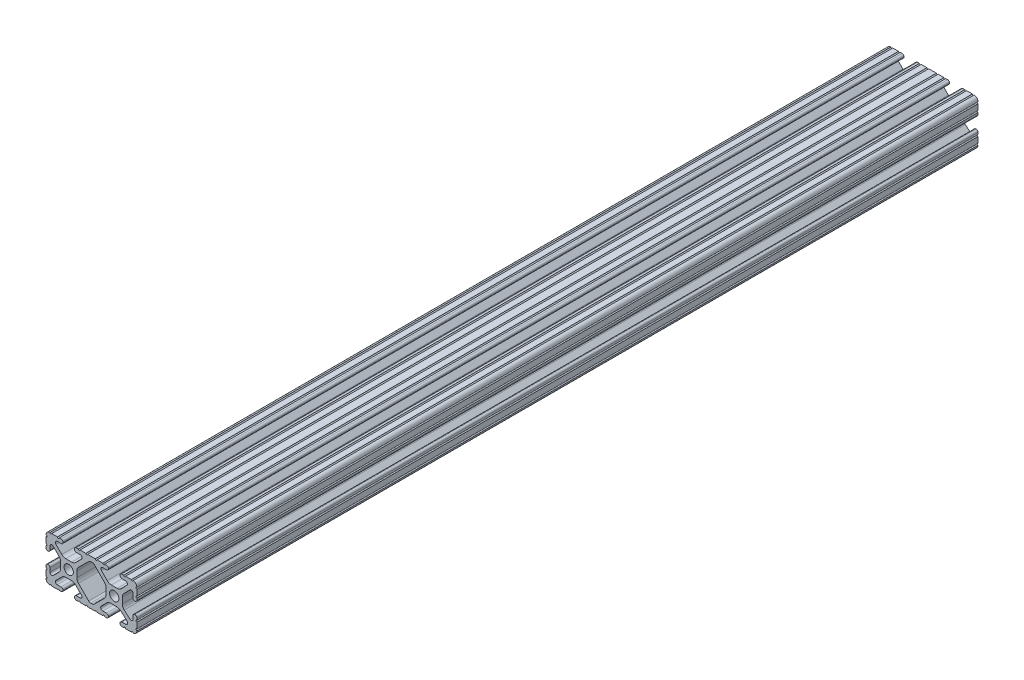
from build123d import *

# Parameters (mm, degrees)
SKETCH1_R      = 2.6035
EXTRUDE1_DEPTH = 235


with BuildPart() as part:
    # Sketch1 → Extrude1 (new body, symmetric)
    with BuildSketch(Plane.XY):
        with BuildLine():
            Line((9.5504, 12.7), (6.33310265, 12.7))
            ThreePointArc((6.33310265, 12.7), (5.82510265, 12.192), (5.31710265, 12.7))
            Line((5.31710265, 12.7), (4.28745015, 12.7))
            ThreePointArc((4.28745015, 12.7), (3.545730386, 12.392769614), (3.2385, 11.65104985))
            Line((3.2385, 11.65104985), (3.2385, 11.53922))
            ThreePointArc((3.2385, 11.53922), (3.545750844, 10.797450844), (4.28752, 10.4902))
            Line((4.28752, 10.4902), (6.416384363, 10.4902))
            ThreePointArc((6.416384363, 10.4902), (7.352502933, 9.869096983), (7.144087081, 8.765172272))
            Line((7.144087081, 8.765172272), (3.918993479, 5.455112286))
            ThreePointArc((3.918993479, 5.455112286), (2.878994274, 4.745442459), (1.644932584, 4.4958))
            Line((1.644932584, 4.4958), (-1.616682165, 4.4958))
            ThreePointArc((-1.616682165, 4.4958), (-2.845669047, 4.743306833), (-3.883044811, 5.447238587))
            Line((-3.883044811, 5.447238587), (-7.135845881, 8.762652677))
            ThreePointArc((-7.135845881, 8.762652677), (-7.347408588, 9.867473037), (-6.410606615, 10.4902))
            Line((-6.410606615, 10.4902), (-4.28752, 10.4902))
            ThreePointArc((-4.28752, 10.4902), (-3.545750844, 10.797450844), (-3.2385, 11.53922))
            Line((-3.2385, 11.53922), (-3.2385, 11.65104985))
            ThreePointArc((-3.2385, 11.65104985), (-3.545730386, 12.392769614), (-4.28745015, 12.7))
            Line((-4.28745015, 12.7), (-5.31711535, 12.7))
            ThreePointArc((-5.31711535, 12.7), (-5.82511535, 12.192), (-6.33311535, 12.7))
            Line((-6.33311535, 12.7), (-9.55041905, 12.7))
            ThreePointArc((-9.55041905, 12.7), (-10.05841905, 12.192), (-10.56641905, 12.7))
            Line((-10.56641905, 12.7), (-14.83358095, 12.7))
            ThreePointArc((-14.83358095, 12.7), (-15.34158095, 12.192), (-15.84958095, 12.7))
            Line((-15.84958095, 12.7), (-19.06689735, 12.7))
            ThreePointArc((-19.06689735, 12.7), (-19.57489735, 12.192), (-20.08289735, 12.7))
            Line((-20.08289735, 12.7), (-21.11254985, 12.7))
            ThreePointArc((-21.11254985, 12.7), (-21.854269614, 12.392769614), (-22.1615, 11.65104985))
            Line((-22.1615, 11.65104985), (-22.1615, 11.53922))
            ThreePointArc((-22.1615, 11.53922), (-21.854249156, 10.797450844), (-21.11248, 10.4902))
            Line((-21.11248, 10.4902), (-18.983641037, 10.4902))
            ThreePointArc((-18.983641037, 10.4902), (-17.997291557, 9.829633109), (-18.232576693, 8.666071843))
            Line((-18.232576693, 8.666071843), (-21.509985098, 5.416263103))
            ThreePointArc((-21.509985098, 5.416263103), (-22.536720513, 4.734920264), (-23.745536121, 4.4958))
            Line((-23.745536121, 4.4958), (-27.054463879, 4.4958))
            ThreePointArc((-27.054463879, 4.4958), (-28.263279487, 4.734920264), (-29.290014902, 5.416263103))
            Line((-29.290014902, 5.416263103), (-32.567423307, 8.666071843))
            ThreePointArc((-32.567423307, 8.666071843), (-32.802708443, 9.829633109), (-31.816358963, 10.4902))
            Line((-31.816358963, 10.4902), (-29.68752, 10.4902))
            ThreePointArc((-29.68752, 10.4902), (-28.945750844, 10.797450844), (-28.6385, 11.53922))
            Line((-28.6385, 11.53922), (-28.6385, 11.65104985))
            ThreePointArc((-28.6385, 11.65104985), (-28.945730386, 12.392769614), (-29.68745015, 12.7))
            Line((-29.68745015, 12.7), (-30.71711535, 12.7))
            ThreePointArc((-30.71711535, 12.7), (-31.22511535, 12.192), (-31.73311535, 12.7))
            Line((-31.73311535, 12.7), (-34.9504, 12.7))
            ThreePointArc((-34.9504, 12.7), (-35.458323491, 12.192000006), (-35.966399977, 12.699846982))
            ThreePointArc((-35.966399977, 12.699846982), (-37.482522516, 12.082522516), (-38.099846982, 10.566399977))
            ThreePointArc((-38.099846982, 10.566399977), (-37.592000006, 10.058323491), (-38.1, 9.5504))
            Line((-38.1, 9.5504), (-38.1, 6.3330836))
            ThreePointArc((-38.1, 6.3330836), (-37.592, 5.8250836), (-38.1, 5.3170836))
            Line((-38.1, 5.3170836), (-38.1, 4.237520184))
            ThreePointArc((-38.1, 4.237520184), (-37.807393763, 3.531106237), (-37.100979816, 3.2385))
            Line((-37.100979816, 3.2385), (-36.93922, 3.2385))
            ThreePointArc((-36.93922, 3.2385), (-36.197450844, 3.545750844), (-35.8902, 4.28752))
            Line((-35.8902, 4.28752), (-35.8902, 6.334741132))
            ThreePointArc((-35.8902, 6.334741132), (-35.256026952, 7.286023527), (-34.134002553, 7.066535717))
            Line((-34.134002553, 7.066535717), (-30.847950853, 3.808156468))
            ThreePointArc((-30.847950853, 3.808156468), (-30.152759693, 2.774838327), (-29.908501877, 1.553619571))
            Line((-29.908501877, 1.553619571), (-29.908501877, -1.695179196))
            ThreePointArc((-29.908501877, -1.695179196), (-30.150738657, -2.911536421), (-30.840486065, -3.942289578))
            Line((-30.840486065, -3.942289578), (-34.131579576, -7.227386226))
            ThreePointArc((-34.131579576, -7.227386226), (-35.25444896, -7.449940594), (-35.8902, -6.498002195))
            Line((-35.8902, -6.498002195), (-35.8902, -4.28752))
            ThreePointArc((-35.8902, -4.28752), (-36.197450844, -3.545750844), (-36.93922, -3.2385))
            Line((-36.93922, -3.2385), (-37.05098, -3.2385))
            ThreePointArc((-37.05098, -3.2385), (-37.792749156, -3.545750844), (-38.1, -4.28752))
            Line((-38.1, -4.28752), (-38.1, -5.3171344))
            ThreePointArc((-38.1, -5.3171344), (-37.592, -5.8251344), (-38.1, -6.3331344))
            Line((-38.1, -6.3331344), (-38.1, -9.5504))
            ThreePointArc((-38.1, -9.5504), (-37.592000006, -10.058323491), (-38.099846982, -10.566399977))
            ThreePointArc((-38.099846982, -10.566399977), (-37.482522516, -12.082522516), (-35.966399977, -12.699846982))
            ThreePointArc((-35.966399977, -12.699846982), (-35.458323491, -12.192000006), (-34.9504, -12.7))
            Line((-34.9504, -12.7), (-31.73308995, -12.7))
            ThreePointArc((-31.73308995, -12.7), (-31.22508995, -12.192), (-30.71708995, -12.7))
            Line((-30.71708995, -12.7), (-29.6874692, -12.7))
            ThreePointArc((-29.6874692, -12.7), (-28.945700044, -12.392749156), (-28.6384492, -11.65098))
            Line((-28.6384492, -11.65098), (-28.6384492, -11.53922))
            ThreePointArc((-28.6384492, -11.53922), (-28.945700044, -10.797450844), (-29.6874692, -10.4902))
            Line((-29.6874692, -10.4902), (-31.816358963, -10.4902))
            ThreePointArc((-31.816358963, -10.4902), (-32.755197748, -9.862578342), (-32.534124023, -8.755124678))
            Line((-32.534124023, -8.755124678), (-29.19660751, -5.423689618))
            ThreePointArc((-29.19660751, -5.423689618), (-28.167274017, -4.736928798), (-26.953591699, -4.4958))
            Line((-26.953591699, -4.4958), (-23.846408301, -4.4958))
            ThreePointArc((-23.846408301, -4.4958), (-22.632725983, -4.736928798), (-21.60339249, -5.423689618))
            Line((-21.60339249, -5.423689618), (-18.265875977, -8.755124678))
            ThreePointArc((-18.265875977, -8.755124678), (-18.044802252, -9.862578342), (-18.983641037, -10.4902))
            Line((-18.983641037, -10.4902), (-21.1125308, -10.4902))
            ThreePointArc((-21.1125308, -10.4902), (-21.854299956, -10.797450844), (-22.1615508, -11.53922))
            Line((-22.1615508, -11.53922), (-22.1615508, -11.65098))
            ThreePointArc((-22.1615508, -11.65098), (-21.854299956, -12.392749156), (-21.1125308, -12.7))
            Line((-21.1125308, -12.7), (-20.08287195, -12.7))
            ThreePointArc((-20.08287195, -12.7), (-19.57487195, -12.192), (-19.06687195, -12.7))
            Line((-19.06687195, -12.7), (-15.84960635, -12.7))
            ThreePointArc((-15.84960635, -12.7), (-15.34160635, -12.192), (-14.83360635, -12.7))
            Line((-14.83360635, -12.7), (-10.56639365, -12.7))
            ThreePointArc((-10.56639365, -12.7), (-10.05840635, -12.1920127), (-9.55041905, -12.7))
            Line((-9.55041905, -12.7), (-6.33308995, -12.7))
            ThreePointArc((-6.33308995, -12.7), (-5.82508995, -12.192), (-5.31708995, -12.7))
            Line((-5.31708995, -12.7), (-4.2874692, -12.7))
            ThreePointArc((-4.2874692, -12.7), (-3.545700044, -12.392749156), (-3.2384492, -11.65098))
            Line((-3.2384492, -11.65098), (-3.2384492, -11.53922))
            ThreePointArc((-3.2384492, -11.53922), (-3.545700044, -10.797450844), (-4.2874692, -10.4902))
            Line((-4.2874692, -10.4902), (-6.410606615, -10.4902))
            ThreePointArc((-6.410606615, -10.4902), (-7.468409678, -9.783049717), (-7.219322755, -8.535265862))
            Line((-7.219322755, -8.535265862), (-4.102066405, -5.423689618))
            ThreePointArc((-4.102066405, -5.423689618), (-3.072732912, -4.736928798), (-1.859050594, -4.4958))
            Line((-1.859050594, -4.4958), (1.402564155, -4.4958))
            ThreePointArc((1.402564155, -4.4958), (2.515927525, -4.697410182), (3.487895372, -5.276636531))
            Line((3.487895372, -5.276636531), (7.168247549, -8.482246082))
            ThreePointArc((7.168247549, -8.482246082), (7.488435806, -9.746879864), (6.416384363, -10.4902))
            Line((6.416384363, -10.4902), (4.2874692, -10.4902))
            ThreePointArc((4.2874692, -10.4902), (3.545700044, -10.797450844), (3.2384492, -11.53922))
            Line((3.2384492, -11.53922), (3.2384492, -11.65098))
            ThreePointArc((3.2384492, -11.65098), (3.545700044, -12.392749156), (4.2874692, -12.7))
            Line((4.2874692, -12.7), (5.31710265, -12.7))
            ThreePointArc((5.31710265, -12.7), (5.82510265, -12.192), (6.33310265, -12.7))
            Line((6.33310265, -12.7), (9.5504, -12.7))
            ThreePointArc((9.5504, -12.7), (10.058323491, -12.192000006), (10.566399977, -12.699846982))
            ThreePointArc((10.566399977, -12.699846982), (12.082522516, -12.082522516), (12.699846982, -10.566399977))
            ThreePointArc((12.699846982, -10.566399977), (12.192000006, -10.058323492), (12.7, -9.550400001))
            Line((12.7, -9.550400001), (12.7, -6.333083592))
            ThreePointArc((12.7, -6.333083592), (12.192000001, -5.825083593), (12.7, -5.317083593))
            Line((12.7, -5.317083593), (12.7, -4.237520184))
            ThreePointArc((12.7, -4.237520184), (12.407393763, -3.531106237), (11.700979816, -3.2385))
            Line((11.700979816, -3.2385), (11.489220184, -3.2385))
            ThreePointArc((11.489220184, -3.2385), (10.782806237, -3.531106237), (10.4902, -4.237520184))
            Line((10.4902, -4.237520184), (10.4902, -6.155876159))
            ThreePointArc((10.4902, -6.155876159), (9.92232736, -7.038258539), (8.883974541, -6.886926384))
            Line((8.883974541, -6.886926384), (5.59817066, -4.024970844))
            ThreePointArc((5.59817066, -4.024970844), (4.793730985, -2.946044689), (4.508501877, -1.630807374))
            Line((4.508501877, -1.630807374), (4.508501877, 1.630807374))
            ThreePointArc((4.508501877, 1.630807374), (4.742348332, 2.82673414), (5.409440981, 3.846495088))
            Line((5.409440981, 3.846495088), (8.826346532, 7.353420386))
            ThreePointArc((8.826346532, 7.353420386), (9.885896263, 7.574939077), (10.4902, 6.676867167))
            Line((10.4902, 6.676867167), (10.4902, 4.237520184))
            ThreePointArc((10.4902, 4.237520184), (10.782806237, 3.531106237), (11.489220184, 3.2385))
            Line((11.489220184, 3.2385), (11.700979816, 3.2385))
            ThreePointArc((11.700979816, 3.2385), (12.407393763, 3.531106237), (12.7, 4.237520184))
            Line((12.7, 4.237520184), (12.7, 5.3170836))
            ThreePointArc((12.7, 5.3170836), (12.191949193, 5.825134407), (12.7, 6.333185215))
            Line((12.7, 6.333185215), (12.7, 9.550400015))
            ThreePointArc((12.7, 9.550400015), (12.192000013, 10.058323498), (12.699846982, 10.566399977))
            ThreePointArc((12.699846982, 10.566399977), (12.082522516, 12.082522516), (10.566399977, 12.699846982))
            ThreePointArc((10.566399977, 12.699846982), (10.058323491, 12.192000006), (9.5504, 12.7))
        make_face()
        with Locations((-25.4, 0)):
            Circle(SKETCH1_R, mode=Mode.SUBTRACT)
        Circle(SKETCH1_R, mode=Mode.SUBTRACT)
        with BuildLine():
            Line((-19.959513935, -3.869413038), (-14.245748891, -9.572766749))
            ThreePointArc((-14.245748891, -9.572766749), (-13.735199478, -9.913400116), (-13.133213048, -10.033))
            Line((-13.133213048, -10.033), (-12.266786952, -10.033))
            ThreePointArc((-12.266786952, -10.033), (-11.664800522, -9.913400116), (-11.154251109, -9.572766749))
            Line((-11.154251109, -9.572766749), (-5.440486065, -3.869413038))
            ThreePointArc((-5.440486065, -3.869413038), (-4.750738657, -2.838659881), (-4.508501877, -1.622302656))
            Line((-4.508501877, -1.622302656), (-4.508501877, 1.622302656))
            ThreePointArc((-4.508501877, 1.622302656), (-4.744426648, 2.823327967), (-5.417139231, 3.845864069))
            Line((-5.417139231, 3.845864069), (-11.024427192, 9.561086461))
            ThreePointArc((-11.024427192, 9.561086461), (-11.538965571, 9.910236611), (-12.148543064, 10.033))
            Line((-12.148543064, 10.033), (-13.095199982, 10.033))
            ThreePointArc((-13.095199982, 10.033), (-13.694772524, 9.914396349), (-14.20403329, 9.576450301))
            Line((-14.20403329, 9.576450301), (-19.952049147, 3.876839553))
            ThreePointArc((-19.952049147, 3.876839553), (-20.647240307, 2.843521412), (-20.891498123, 1.622302656))
            Line((-20.891498123, 1.622302656), (-20.891498123, -1.622302656))
            ThreePointArc((-20.891498123, -1.622302656), (-20.649261343, -2.838659881), (-19.959513935, -3.869413038))
        make_face(mode=Mode.SUBTRACT)
    extrude(amount=EXTRUDE1_DEPTH, both=True)


solid = part.part
